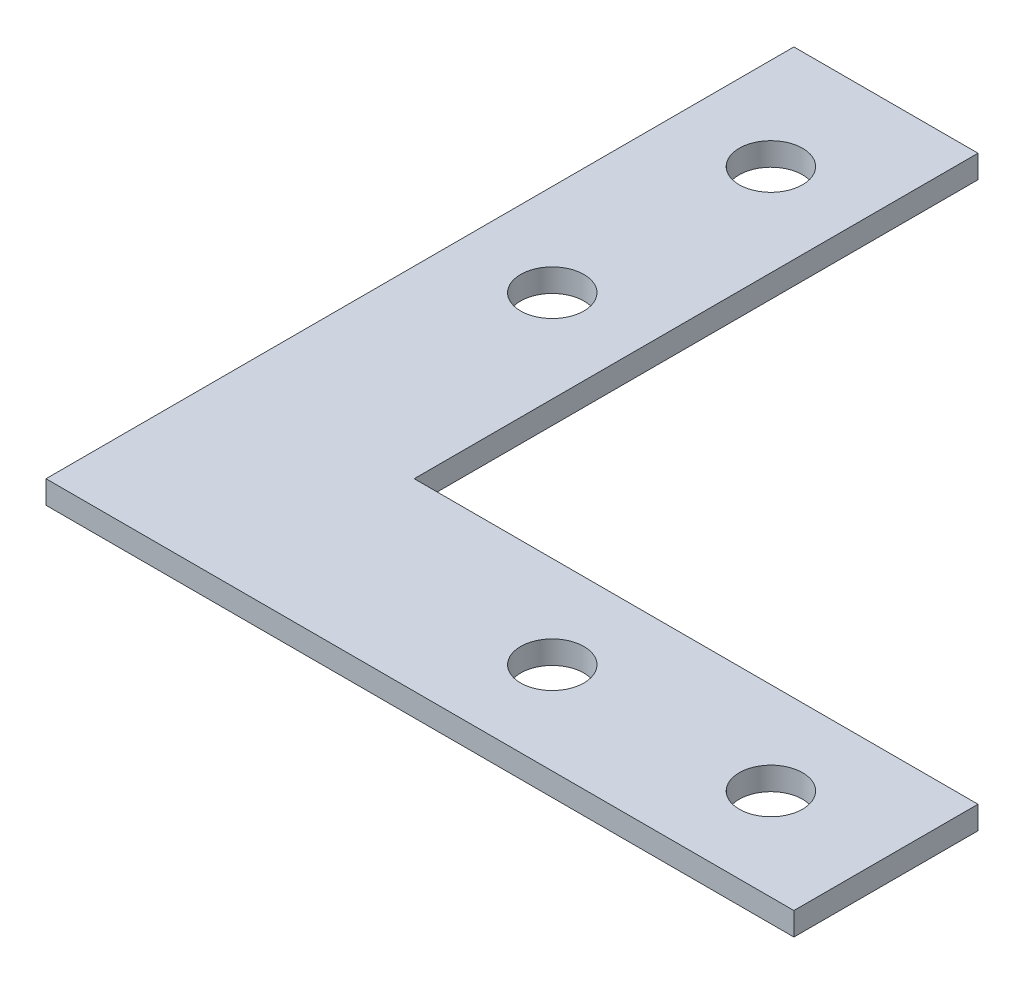
from build123d import *

# Parameters (mm, degrees)
SKETCH_1_R      = 2.75
EXTRUDE_1_DEPTH = 2


with BuildPart() as part:
    # 草图1 → 凸台-拉伸1 (new body)
    with BuildSketch(Plane(origin=(0, 0, 0), x_dir=(1, 0, 0), z_dir=(0, 1, 0))):
        Polygon((0, 0), (0, 65), (16, 65), (16, 16), (65, 16), (65, 0), align=None)
        with Locations((8, 55)):
            Circle(SKETCH_1_R, mode=Mode.SUBTRACT)
        with Locations((8, 36)):
            Circle(SKETCH_1_R, mode=Mode.SUBTRACT)
        with Locations((36, 8)):
            Circle(SKETCH_1_R, mode=Mode.SUBTRACT)
        with Locations((55, 8)):
            Circle(SKETCH_1_R, mode=Mode.SUBTRACT)
    extrude(amount=EXTRUDE_1_DEPTH)


solid = part.part
